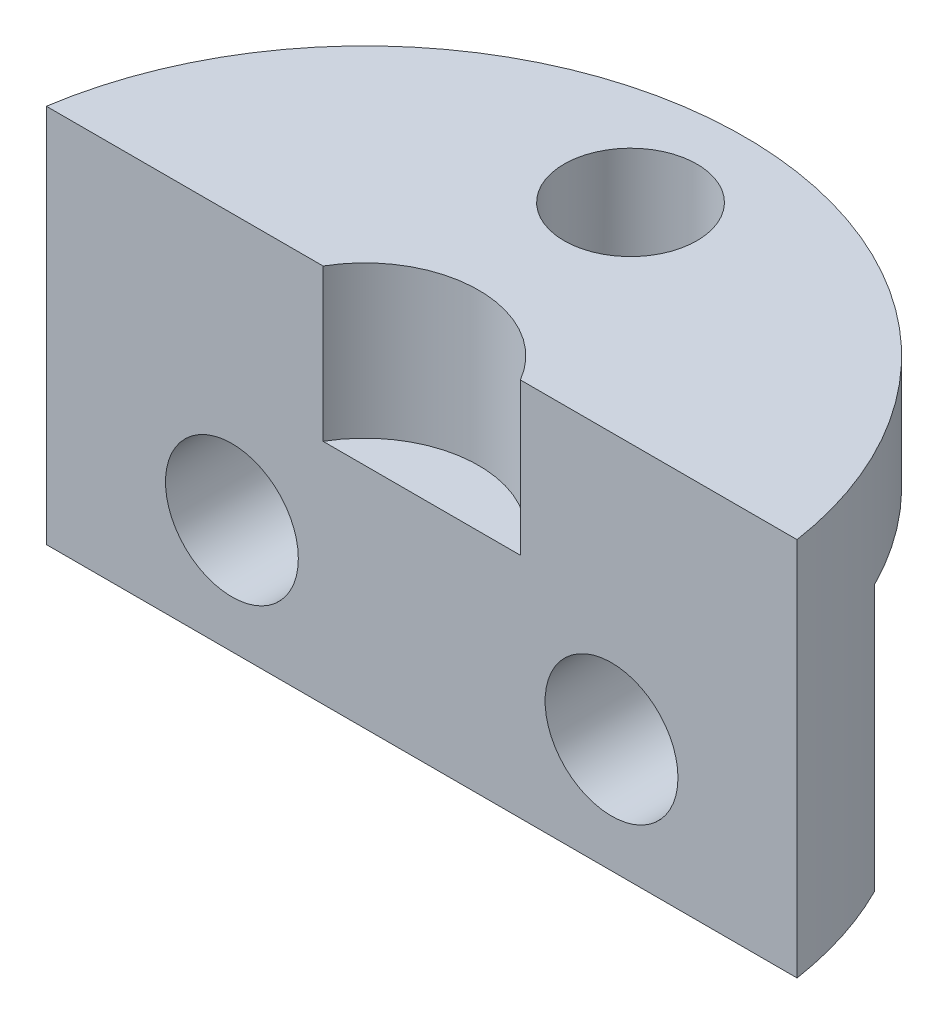
from build123d import *

# Parameters (mm, degrees)
SKETCH_1_R               = 10
EXTRUDE_1_DEPTH          = 10
CUT_EXTRUDE_1_DEPTH      = 10
CUT_EXTRUDE_1_DEPTH_BACK = 10
SKETCH_2_W               = 27.353123027
SKETCH_2_H               = 11.793746162
SKETCH_3_R               = 1.75
CUT_EXTRUDE_2_DEPTH      = 18.255433927
SKETCH_4_R               = 3
CUT_EXTRUDE_3_DEPTH      = 4
SKETCH_5_W               = 23.260827415
SKETCH_5_H               = 7
CUT_EXTRUDE_5_DEPTH      = 7
SKETCH_6_R               = 1.75
CUT_EXTRUDE_6_DEPTH      = 7


with BuildPart() as part:
    # Эскиз1 → Бобышка-Вытянуть1 (new body)
    with BuildSketch(Plane(origin=(0, 0, 0), x_dir=(1, 0, 0), z_dir=(0, 1, 0))):
        Circle(SKETCH_1_R)
    extrude(amount=EXTRUDE_1_DEPTH)

    # Эскиз2 → Вырез-Вытянуть1 (cut, two sides: drawn at the far end of the back side and taken through both)
    with BuildSketch(Plane(origin=(0, 0, 0), x_dir=(1, 0, 0), z_dir=(0, 1, 0)).offset(-CUT_EXTRUDE_1_DEPTH_BACK)):
        with Locations((1.294435554, -4.396873081)):
            Rectangle(SKETCH_2_W, SKETCH_2_H)
    extrude(amount=CUT_EXTRUDE_1_DEPTH + CUT_EXTRUDE_1_DEPTH_BACK, mode=Mode.SUBTRACT)

    # Эскиз3 → Вырез-Вытянуть2 (cut, through all)
    with BuildSketch(Plane(origin=(0, 10, 0), x_dir=(1, 0, 0), z_dir=(0, 1, 0))):
        with Locations((0, 7)):
            Circle(SKETCH_3_R)
    extrude(amount=-CUT_EXTRUDE_2_DEPTH, mode=Mode.SUBTRACT)

    # Эскиз4 → Вырез-Вытянуть3 (cut)
    with BuildSketch(Plane(origin=(0, 10, 0), x_dir=(1, 0, 0), z_dir=(0, 1, 0))):
        Circle(SKETCH_4_R)
    extrude(amount=-CUT_EXTRUDE_3_DEPTH, mode=Mode.SUBTRACT)

    # Эскиз5 → Вырез-Вытянуть5 (cut)
    with BuildSketch(Plane.XZ):
        with Locations((0.625951198, -8)):
            Rectangle(SKETCH_5_W, SKETCH_5_H)
    extrude(amount=-CUT_EXTRUDE_5_DEPTH, mode=Mode.SUBTRACT)

    # Эскиз6 → Вырез-Вытянуть6 (cut)
    with BuildSketch(Plane.XY.offset(-1.5)):
        with Locations((-5, 3)):
            Circle(SKETCH_6_R)
        with Locations((5, 3)):
            Circle(SKETCH_6_R)
    extrude(amount=-CUT_EXTRUDE_6_DEPTH, mode=Mode.SUBTRACT)


solid = part.part
